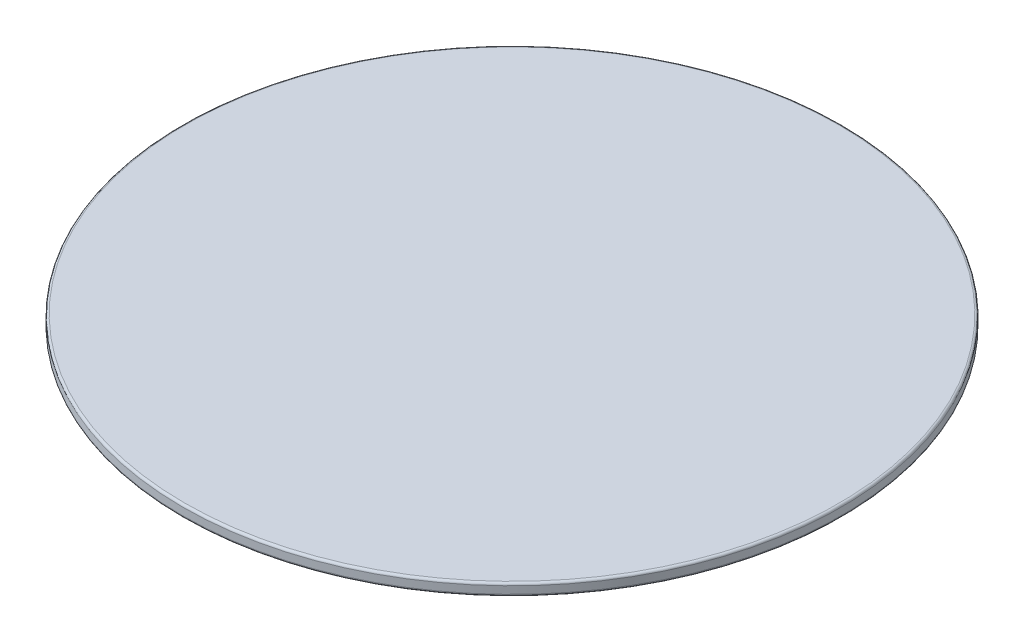
from build123d import *

# Parameters (mm, degrees)
SKETCH1_R           = 145
BOSS_EXTRUDE1_DEPTH = 5.25
FILLET1_R           = 1


with BuildPart() as part:
    # Sketch1 → Boss-Extrude1 (new body)
    with BuildSketch(Plane(origin=(0, 0, 0), x_dir=(1, 0, 0), z_dir=(0, 1, 0))):
        Circle(SKETCH1_R)
    extrude(amount=BOSS_EXTRUDE1_DEPTH)

    # Fillet1
    fillet1_edges = [part.edges().sort_by_distance(p)[0] for p in [
        (-145, 0, 0),
        (-145, 5.25, 0),
    ]]
    fillet(fillet1_edges, radius=FILLET1_R)


solid = part.part
